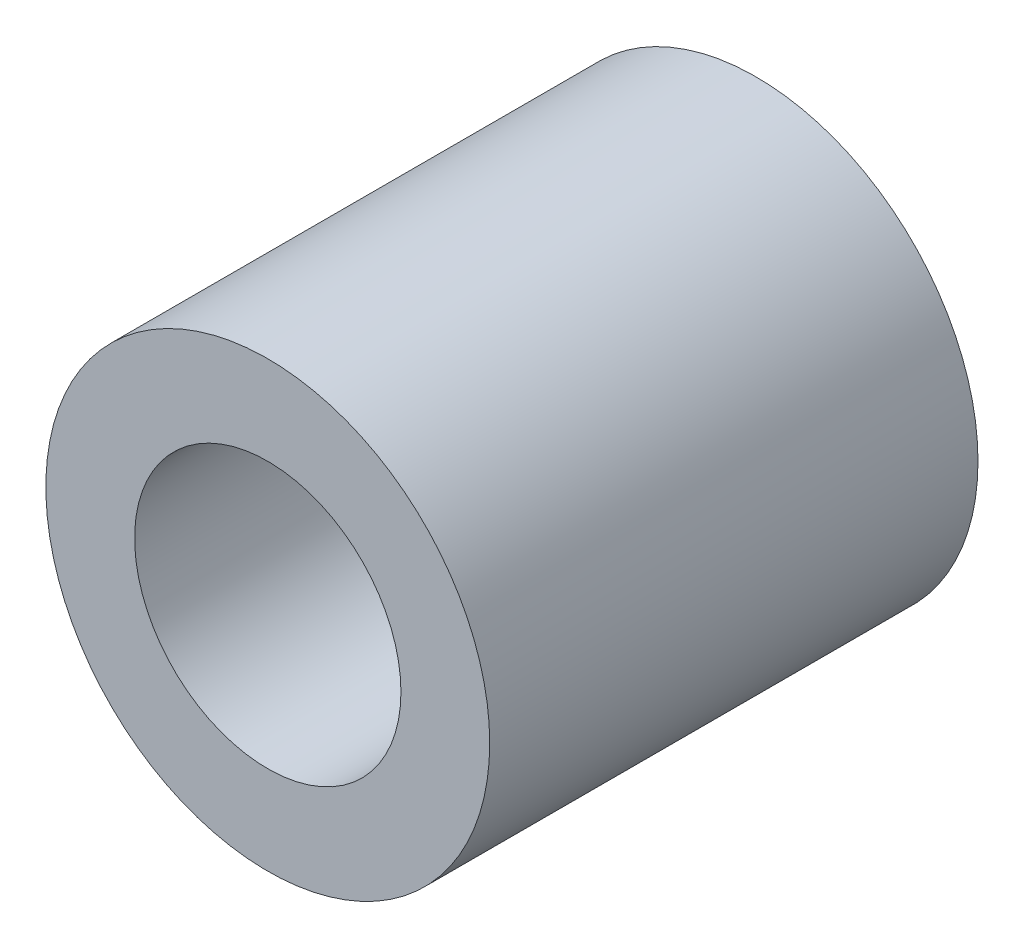
from build123d import *

# Parameters (mm, degrees)
ESQUISSE1_R        = 25
ESQUISSE1_R_2      = 15
BOSS_EXTRU_1_DEPTH = 55


with BuildPart() as part:
    # Esquisse1 → Boss.-Extru.1 (new body)
    with BuildSketch(Plane.XY):
        Circle(ESQUISSE1_R)
        Circle(ESQUISSE1_R_2, mode=Mode.SUBTRACT)
    extrude(amount=BOSS_EXTRU_1_DEPTH)


solid = part.part
